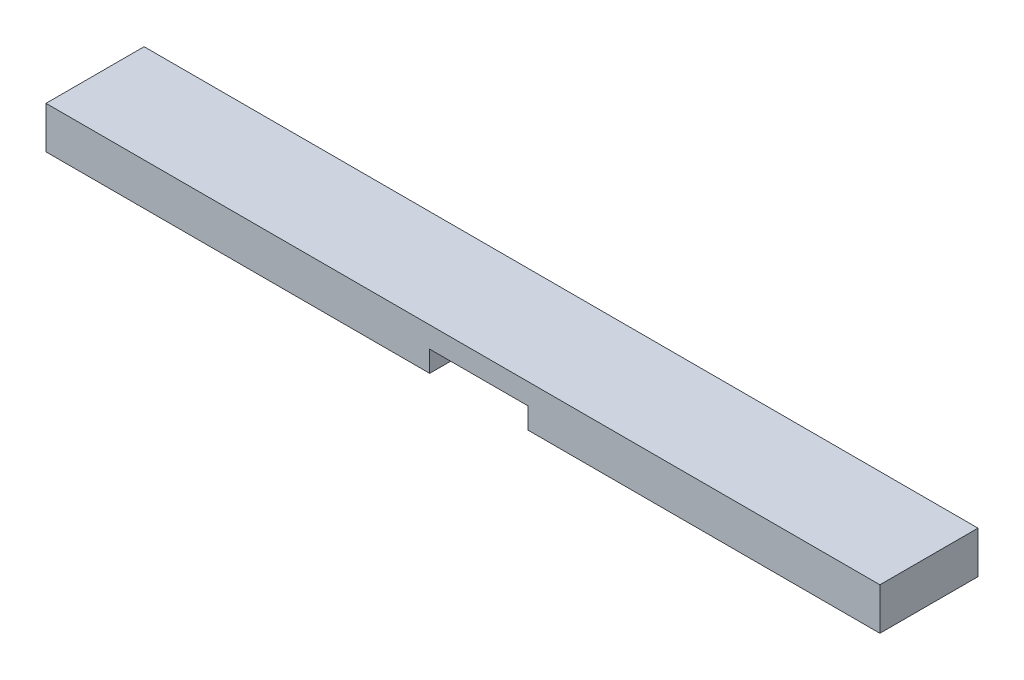
from build123d import *

# Parameters (mm, degrees)
SKETCH1_W           = 755.65
SKETCH1_H           = 88.9
BOSS_EXTRUDE1_DEPTH = 38.1
SKETCH2_W           = 88.9
SKETCH2_H           = 88.9
CUT_EXTRUDE1_DEPTH  = 19.05


with BuildPart() as part:
    # Sketch1 → Boss-Extrude1 (new body)
    with BuildSketch(Plane(origin=(0, 0, 0), x_dir=(1, 0, 0), z_dir=(0, 1, 0))):
        with Locations((377.825, 44.45)):
            Rectangle(SKETCH1_W, SKETCH1_H)
    extrude(amount=BOSS_EXTRUDE1_DEPTH)

    # Sketch2 → Cut-Extrude1 (cut)
    with BuildSketch(Plane.XZ):
        with Locations((392.1252, -44.45)):
            Rectangle(SKETCH2_W, SKETCH2_H)
    extrude(amount=-CUT_EXTRUDE1_DEPTH, mode=Mode.SUBTRACT)


solid = part.part
